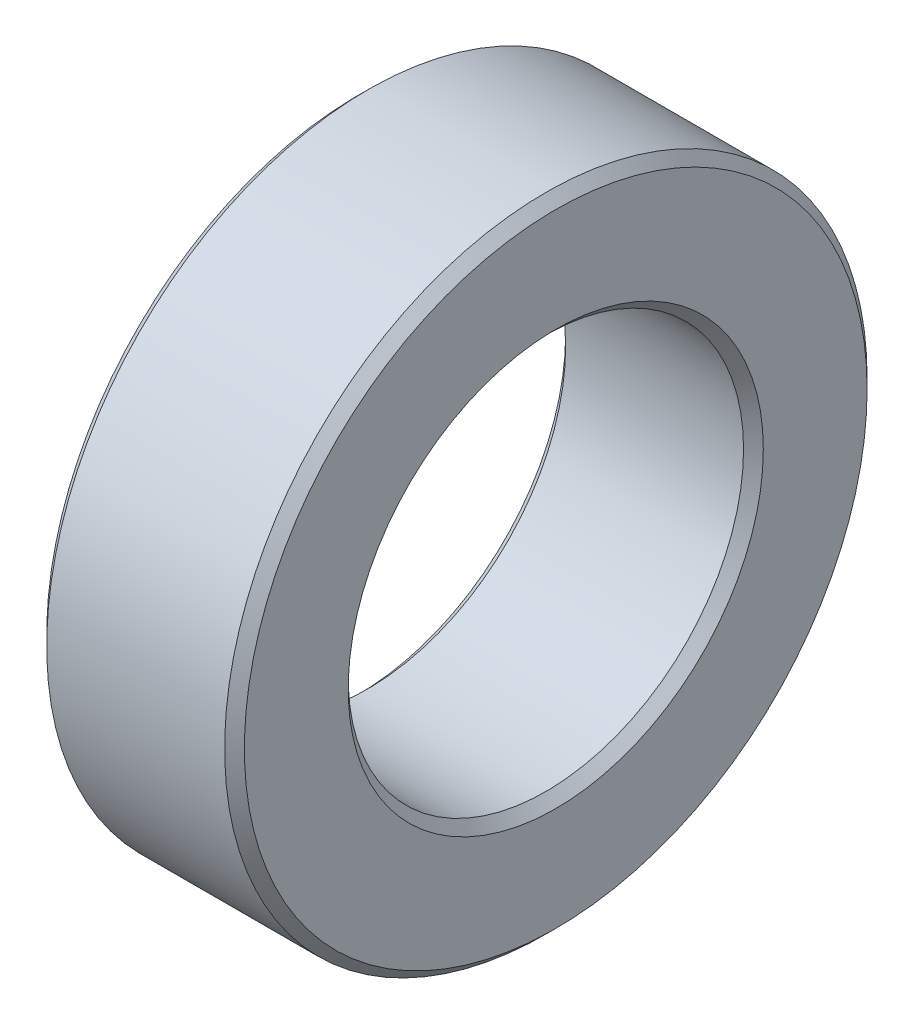
from build123d import *

# Parameters (mm, degrees)
SKETCH1_R           = 6.5
SKETCH1_R_2         = 4
BOSS_EXTRUDE1_DEPTH = 4
CHAMFER1_SIZE       = 0.2


with BuildPart() as part:
    # Sketch1 → Boss-Extrude1 (new body)
    with BuildSketch(Plane(origin=(0, 0, 0), x_dir=(0, 0, -1), z_dir=(1, 0, 0))):
        Circle(SKETCH1_R)
        Circle(SKETCH1_R_2, mode=Mode.SUBTRACT)
    extrude(amount=BOSS_EXTRUDE1_DEPTH)

    # Chamfer1
    chamfer1_edges = [part.edges().sort_by_distance(p)[0] for p in [
        (0, 0, 6.5),
        (4, 0, 6.5),
        (0, 0, 4),
        (4, 0, 4),
    ]]
    chamfer(chamfer1_edges, length=CHAMFER1_SIZE)


solid = part.part
